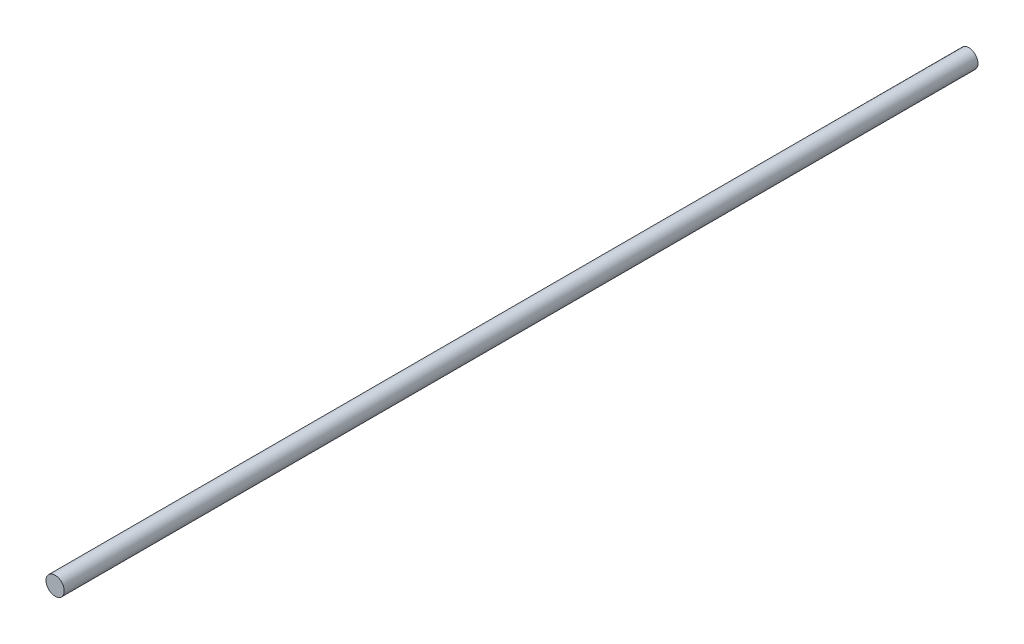
from build123d import *

# Parameters (mm, degrees)
SKETCH1_R           = 4
BOSS_EXTRUDE1_DEPTH = 200


with BuildPart() as part:
    # Sketch1 → Boss-Extrude1 (new body, symmetric)
    with BuildSketch(Plane.XY):
        Circle(SKETCH1_R)
    extrude(amount=BOSS_EXTRUDE1_DEPTH, both=True)


solid = part.part
